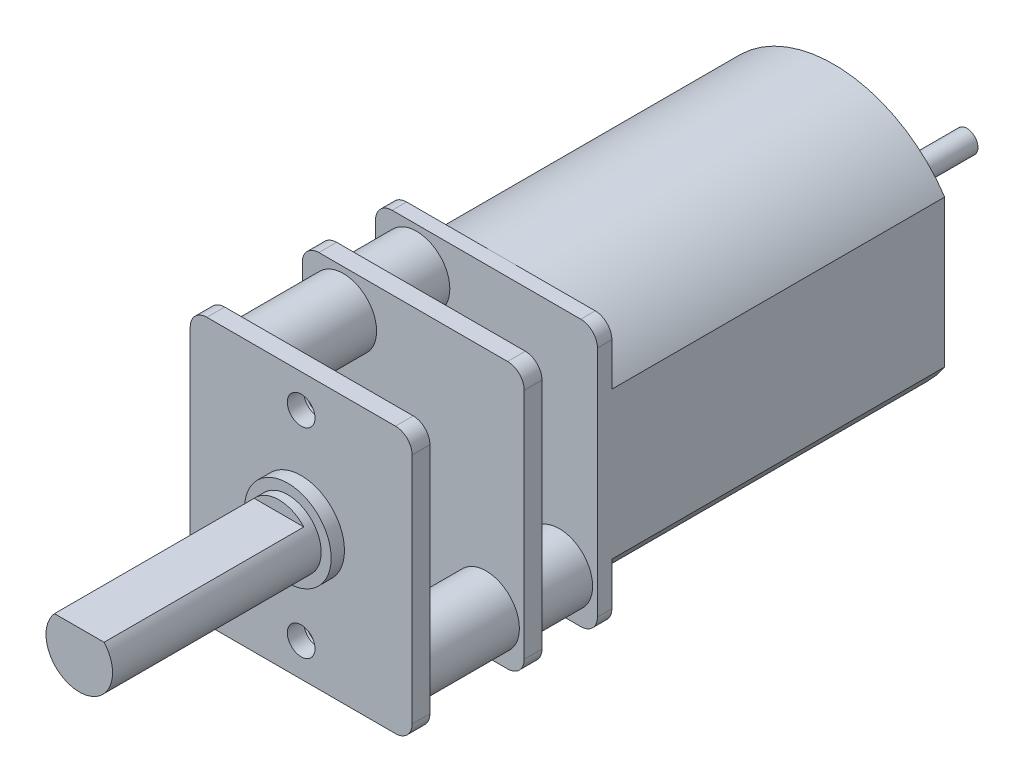
from build123d import *

# Parameters (mm, degrees)
SKETCH1_W                    = 10
SKETCH1_H                    = 12
BOSS_EXTRUDE1_DEPTH          = 9
BOSS_EXTRUDE2_DEPTH          = 15
CUT_EXTRUDE1_DEPTH           = 9
FILLET1_R                    = 0.75
M1_6X0_35_TAPPED_HOLE1_D     = 1.25
M1_6X0_35_TAPPED_HOLE1_DEPTH = 0.75
M1_6X0_35_TAPPED_HOLE1_TIP   = 0.375537887
CUT_EXTRUDE2_START           = -0.8
SKETCH7_W                    = 10
SKETCH7_H                    = 12
SKETCH7_R                    = 1.5
CUT_EXTRUDE2_DEPTH           = 4.25
CUT_EXTRUDE3_START           = -0.8
SKETCH8_W                    = 10
SKETCH8_H                    = 12
SKETCH8_R                    = 1.5
CUT_EXTRUDE3_DEPTH           = 2.5


with BuildPart() as part:
    # Sketch1 → Boss-Extrude1 (new body)
    with BuildSketch(Plane.XY):
        Rectangle(SKETCH1_W, SKETCH1_H)
    extrude(amount=-BOSS_EXTRUDE1_DEPTH)

    # Sketch2 → Boss-Extrude2 (add)
    with BuildSketch(Plane(origin=(0, 0, -9), x_dir=(-1, 0, 0), z_dir=(0, 0, -1))):
        with BuildLine():
            Line((-5, 3.31662479), (-5, -3.31662479))
            ThreePointArc((-5, -3.31662479), (0, -6), (5, -3.31662479))
            Line((5, -3.31662479), (5, 3.31662479))
            ThreePointArc((5, 3.31662479), (0, 6), (-5, 3.31662479))
        make_face()
    extrude(amount=BOSS_EXTRUDE2_DEPTH)

    # Sketch3 → Revolve1 (revolve)
    with BuildSketch(Plane(origin=(0, 0, 0), x_dir=(0, 0, -1), z_dir=(1, 0, 0))):
        Polygon((-10, 0), (30, 0), (30, 0.5), (24.524329041, 0.5), (24.524329041, 0.797163214), (25.5, 0.797163214), (25.5, 2.5), (0, 2.5), (0, 1.95), (-0.6, 1.95), (-0.6, 1.5), (-10, 1.5), align=None)
    revolve(axis=Axis((0, 0, 10), (0, 0, -1)))

    # Sketch4 → Cut-Extrude1 (cut)
    with BuildSketch(Plane.XY.offset(10)):
        with BuildLine():
            Line((1.118033989, 1), (-1.118033989, 1))
            ThreePointArc((-1.118033989, 1), (0, 1.5), (1.118033989, 1))
        make_face()
    extrude(amount=-CUT_EXTRUDE1_DEPTH, mode=Mode.SUBTRACT)

    # Fillet1
    fillet1_edges = [part.edges().sort_by_distance(p)[0] for p in [
        (-5, -6, -4.5),
        (5, -6, -4.5),
        (5, 6, -4.5),
        (-5, 6, -4.5),
    ]]
    fillet(fillet1_edges, radius=FILLET1_R)

    # M1.6x0.35 Tapped Hole1
    with Locations(Plane.XY):
        with Locations((0, -4.5), (0, 4.5)):
            Hole(M1_6X0_35_TAPPED_HOLE1_D / 2, depth=M1_6X0_35_TAPPED_HOLE1_DEPTH)
            with Locations((0, 0, -(M1_6X0_35_TAPPED_HOLE1_DEPTH + M1_6X0_35_TAPPED_HOLE1_TIP / 2))):  # 118° drill point
                Cone(0, M1_6X0_35_TAPPED_HOLE1_D / 2, M1_6X0_35_TAPPED_HOLE1_TIP, mode=Mode.SUBTRACT)

    # Sketch7 → Cut-Extrude2 (cut)
    with BuildSketch(Plane.XY.offset(CUT_EXTRUDE2_START)):
        Rectangle(SKETCH7_W, SKETCH7_H)
        with Locations((-3.151875275, 4.232117394)):
            Circle(SKETCH7_R, mode=Mode.SUBTRACT)
        with Locations((3.282813714, -4.157295429)):
            Circle(SKETCH7_R, mode=Mode.SUBTRACT)
    extrude(amount=-CUT_EXTRUDE2_DEPTH, mode=Mode.SUBTRACT)

    # Sketch8 → Cut-Extrude3 (cut)
    with BuildSketch(Plane.XY.offset(-5.05).offset(CUT_EXTRUDE3_START)):
        Rectangle(SKETCH8_W, SKETCH8_H)
        with Locations((-3.151875275, 4.232117394)):
            Circle(SKETCH8_R, mode=Mode.SUBTRACT)
        with Locations((3.282813714, -4.157295429)):
            Circle(SKETCH8_R, mode=Mode.SUBTRACT)
    extrude(amount=-CUT_EXTRUDE3_DEPTH, mode=Mode.SUBTRACT)


solid = part.part
